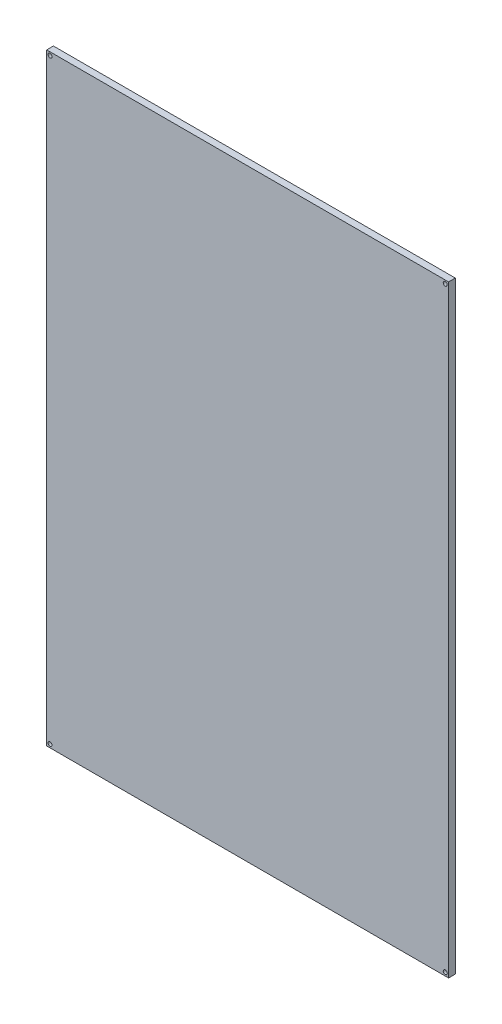
from build123d import *

# Parameters (mm, degrees)
SKETCH1_W           = 300
SKETCH1_H           = 450
BOSS_EXTRUDE1_DEPTH = 5
SKETCH2_R           = 1.5
CUT_EXTRUDE1_DEPTH  = 6


with BuildPart() as part:
    # Sketch1 → Boss-Extrude1 (new body)
    with BuildSketch(Plane.XY):
        Rectangle(SKETCH1_W, SKETCH1_H)
    extrude(amount=BOSS_EXTRUDE1_DEPTH)

    # Sketch2 → Cut-Extrude1 (cut, through all)
    with BuildSketch(Plane.XY.offset(5)):
        with Locations((-147.5, -222.5)):
            Circle(SKETCH2_R)
        with Locations((-147.5, 222.5)):
            Circle(SKETCH2_R)
        with Locations((147.5, -222.5)):
            Circle(SKETCH2_R)
        with Locations((147.5, 222.5)):
            Circle(SKETCH2_R)
    extrude(amount=-CUT_EXTRUDE1_DEPTH, mode=Mode.SUBTRACT)


solid = part.part
